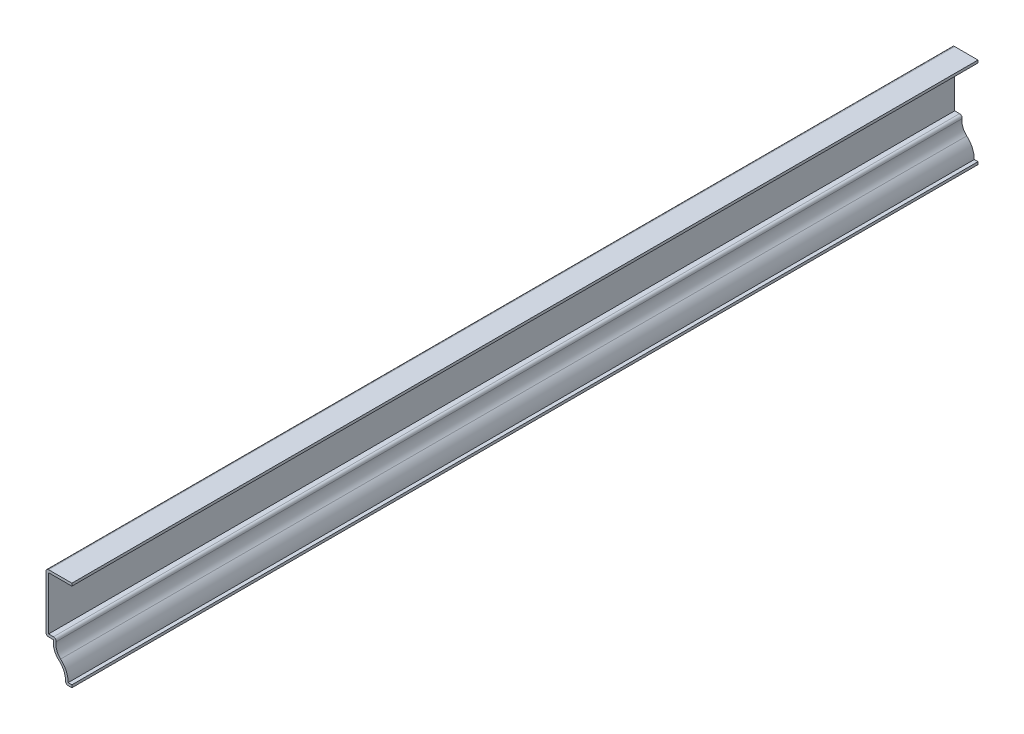
from build123d import *

# Parameters (mm, degrees)
EXTRUDE_THIN1_DEPTH = 444.5
FILLET1_R           = 1.27


with BuildPart() as part:
    # Sketch1 → Extrude-Thin1 (new body)
    with BuildSketch(Plane.XY):
        with BuildLine():
            Line((0, 0), (-3.175, 0))
            ThreePointArc((-3.175, 0), (-3.702847988, 4.644874913), (-6.360025415, 8.491028131))
            ThreePointArc((-6.360025415, 8.491028131), (-8.643825609, 11.839848435), (-9.028393687, 15.875))
            Line((-9.028393687, 15.875), (-12.7, 15.875))
            Line((-12.7, 15.875), (-12.7, 44.45))
            Line((-12.7, 44.45), (0, 44.45))
            Line((0, 44.45), (0, 43.18))
            Line((0, 43.18), (-11.43, 43.18))
            Line((-11.43, 43.18), (-11.43, 17.145))
            Line((-11.43, 17.145), (-7.371031325, 17.145))
            ThreePointArc((-7.371031325, 17.145), (-7.668334251, 13.001809097), (-5.522110789, 9.445386071))
            ThreePointArc((-5.522110789, 9.445386071), (-2.789162607, 5.757129719), (-1.820706321, 1.27))
            Line((-1.820706321, 1.27), (0, 1.27))
            Line((0, 1.27), (0, 0))
        make_face()
    extrude(amount=-EXTRUDE_THIN1_DEPTH)

    # Fillet1
    fillet1_edges = [part.edges().sort_by_distance(p)[0] for p in [
        (-7.371031325, 17.145, -222.25),
        (-3.175, 0, -222.25),
        (-12.7, 15.875, -222.25),
        (-12.7, 44.45, -222.25),
    ]]
    fillet(fillet1_edges, radius=FILLET1_R)


solid = part.part
